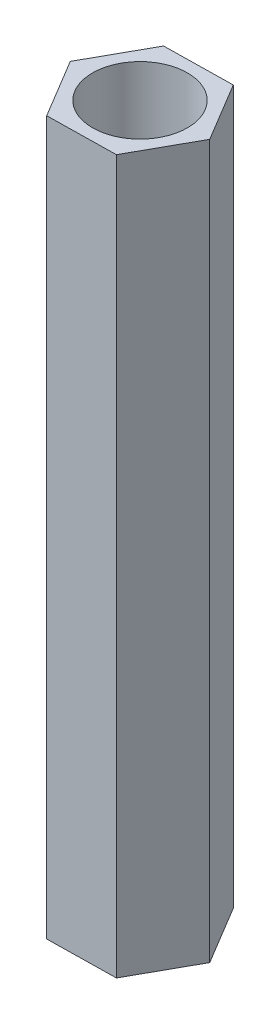
from build123d import *

# Parameters (mm, degrees)
SKETCH_1_R      = 2
EXTRUDE_1_DEPTH = 30


with BuildPart() as part:
    # 草图1 → 凸台-拉伸1 (new body)
    with BuildSketch(Plane(origin=(0, 0, 0), x_dir=(1, 0, 0), z_dir=(0, 1, 0))):
        Polygon((1.401930385, 2.523474693), (-1.484427998, 2.475844675), (-2.886358383, -0.047630019), (-1.401930385, -2.523474693), (1.484427998, -2.475844675), (2.886358383, 0.047630019), align=None)
        Circle(SKETCH_1_R, mode=Mode.SUBTRACT)
    extrude(amount=EXTRUDE_1_DEPTH)


solid = part.part
